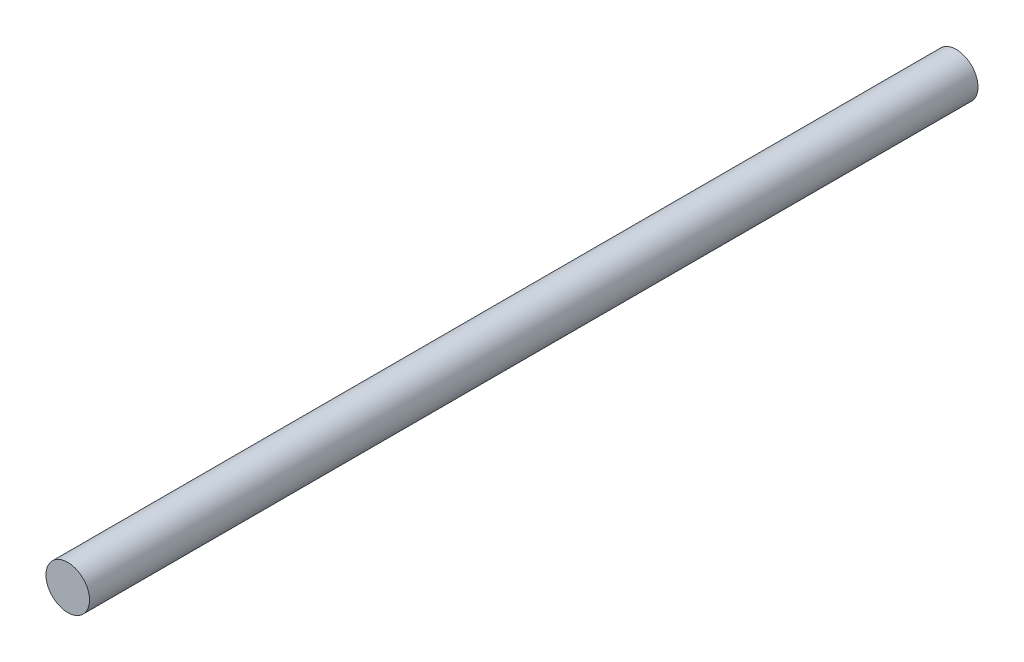
from build123d import *

# Parameters (mm, degrees)
SKETCH1_R           = 2.5
BOSS_EXTRUDE1_DEPTH = 102


with BuildPart() as part:
    # Sketch1 → Boss-Extrude1 (new body)
    with BuildSketch(Plane.XY):
        Circle(SKETCH1_R)
    extrude(amount=-BOSS_EXTRUDE1_DEPTH)


solid = part.part
